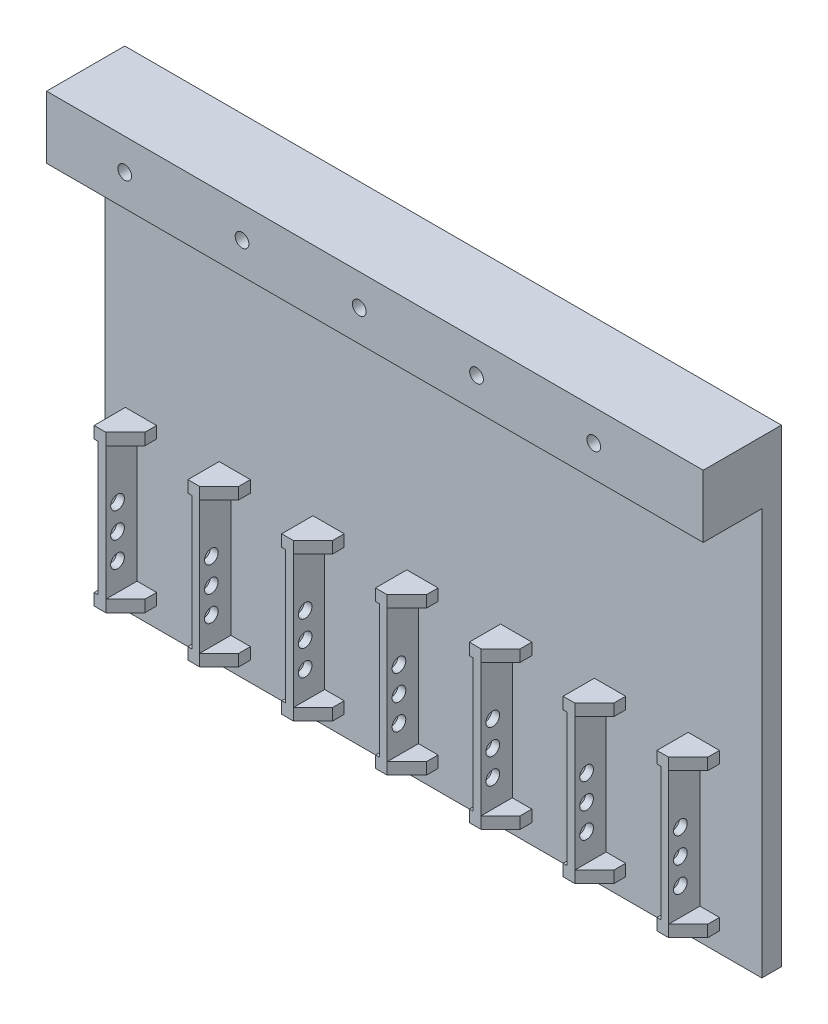
from build123d import *

# Parameters (mm, degrees)
SKETCH1_W                  = 168
SKETCH1_H                  = 120
BOSS_EXTRUDE1_DEPTH        = 20
SKETCH2_W                  = 168
SKETCH2_H                  = 104
CUT_EXTRUDE1_DEPTH         = 15
SKETCH3_R                  = 1.75
CUT_EXTRUDE2_DEPTH         = 21
SKETCH5_W                  = 2
SKETCH5_H                  = 40
BOSS_EXTRUDE2_DEPTH        = 8
SKETCH6_R                  = 1.75
CUT_EXTRUDE3_DEPTH         = 162.85
SKETCH7_W                  = 8
SKETCH7_H                  = 3
BOSS_EXTRUDE3_DEPTH        = 8
CHAMFER1_SIZE              = 5
LPATTERN1_COUNT            = 7
LPATTERN1_PITCH            = 24
CHAMFER1_OF_LPATTERN1_SIZE = 5


with BuildPart() as part:
    # Sketch1 → Boss-Extrude1 (new body)
    with BuildSketch(Plane.XY):
        Rectangle(SKETCH1_W, SKETCH1_H)
    extrude(amount=BOSS_EXTRUDE1_DEPTH)

    # Sketch2 → Cut-Extrude1 (cut)
    with BuildSketch(Plane.XY.offset(20)):
        with Locations((0, -8)):
            Rectangle(SKETCH2_W, SKETCH2_H)
    extrude(amount=-CUT_EXTRUDE1_DEPTH, mode=Mode.SUBTRACT)

    # Sketch3 → Cut-Extrude2 (cut, through all)
    with BuildSketch(Plane.XY.offset(20)):
        with Locations((-64, 52)):
            Circle(SKETCH3_R)
        with Locations((-34, 52)):
            Circle(SKETCH3_R)
        with Locations((-4, 52)):
            Circle(SKETCH3_R)
        with Locations((26, 52)):
            Circle(SKETCH3_R)
        with Locations((56, 52)):
            Circle(SKETCH3_R)
    extrude(amount=-CUT_EXTRUDE2_DEPTH, mode=Mode.SUBTRACT)

    # Sketch5 → Boss-Extrude2 (add)
    with BuildSketch(Plane.XY.offset(5)):
        with Locations((-76.85, -35)):
            Rectangle(SKETCH5_W, SKETCH5_H)
    boss_extrude2 = extrude(amount=BOSS_EXTRUDE2_DEPTH)

    # Sketch6 → Cut-Extrude3 (cut, through all)
    with BuildSketch(Plane.ZY.offset(77.85)):
        with Locations((10, -45)):
            Circle(SKETCH6_R)
        with Locations((10, -38.5)):
            Circle(SKETCH6_R)
        with Locations((10, -32)):
            Circle(SKETCH6_R)
    cut_extrude3 = extrude(amount=-CUT_EXTRUDE3_DEPTH, mode=Mode.SUBTRACT)

    # Sketch7 → Boss-Extrude3 (add)
    with BuildSketch(Plane.XY.offset(5)):
        with Locations((-74.85, -53.5)):
            Rectangle(SKETCH7_W, SKETCH7_H)
        with Locations((-74.85, -16.5)):
            Rectangle(SKETCH7_W, SKETCH7_H)
    boss_extrude3 = extrude(amount=BOSS_EXTRUDE3_DEPTH)

    # Chamfer1
    chamfer1_edges = [part.edges().sort_by_distance(p)[0] for p in [
        (-70.85, -16.5, 13),
        (-70.85, -53.5, 13),
    ]]
    chamfer(chamfer1_edges, length=CHAMFER1_SIZE)

    # LPattern1: Boss-Extrude2, Cut-Extrude3, Boss-Extrude3 ×7
    with Locations(*[(i * LPATTERN1_PITCH, 0, 0) for i in range(1, LPATTERN1_COUNT)]):
        add(boss_extrude2)
        add(cut_extrude3, mode=Mode.SUBTRACT)
        add(boss_extrude3)

    # Chamfer1 of LPattern1
    chamfer1_of_lpattern1_edges = [part.edges().sort_by_distance(p)[0] for p in [
        (-46.85, -16.5, 13),
        (-46.85, -53.5, 13),
        (-22.85, -16.5, 13),
        (-22.85, -53.5, 13),
        (1.15, -16.5, 13),
        (1.15, -53.5, 13),
        (25.15, -16.5, 13),
        (25.15, -53.5, 13),
        (49.15, -16.5, 13),
        (49.15, -53.5, 13),
        (73.15, -16.5, 13),
        (73.15, -53.5, 13),
    ]]
    chamfer(chamfer1_of_lpattern1_edges, length=CHAMFER1_OF_LPATTERN1_SIZE)


solid = part.part
